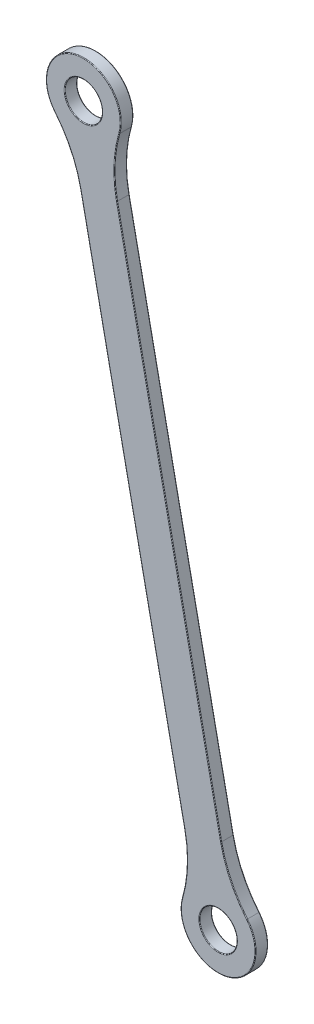
from build123d import *

# Parameters (mm, degrees)
SZKIC2_R                    = 4.5
DODANIE_WYCI_GNI_CIE1_DEPTH = 3
ZAOKR_GLENIE1_R             = 30
ZAOKR_GLENIE2_R             = 30
ZAOKR_GLENIE3_R             = 30
ZAOKR_GLENIE4_R             = 30
ZAOKR_GLENIE5_R             = 0.15


with BuildPart() as part:
    # Szkic2 → Dodanie-wyciągnięcie1 (new body)
    with BuildSketch(Plane.XY):
        with BuildLine():
            ThreePointArc((27.792879551, 56.476790511), (35.605147637, 40.944096516), (36.605872011, 58.301938148))
            Line((36.605872011, 58.301938148), (7.320051345, 199.712808955))
            ThreePointArc((7.320051345, 199.712808955), (-0.492216741, 215.24550295), (-1.492941115, 197.887661317))
            Line((-1.492941115, 197.887661317), (27.792879551, 56.476790511))
        make_face()
        with Locations((33.78, 49.757088976)):
            Circle(SZKIC2_R, mode=Mode.SUBTRACT)
        with Locations((1.332930896, 206.43251049)):
            Circle(SZKIC2_R, mode=Mode.SUBTRACT)
    extrude(amount=DODANIE_WYCI_GNI_CIE1_DEPTH)

    # Zaokrąglenie1
    zaokr_glenie1_edges = [part.edges().sort_by_distance(p)[0] for p in [
        (-1.492941115, 197.887661317, 1.5),
    ]]
    fillet(zaokr_glenie1_edges, radius=ZAOKR_GLENIE1_R)

    # Zaokrąglenie2
    zaokr_glenie2_edges = [part.edges().sort_by_distance(p)[0] for p in [
        (7.320051345, 199.712808955, 1.5),
    ]]
    fillet(zaokr_glenie2_edges, radius=ZAOKR_GLENIE2_R)

    # Zaokrąglenie3
    zaokr_glenie3_edges = [part.edges().sort_by_distance(p)[0] for p in [
        (27.792879551, 56.476790511, 1.5),
    ]]
    fillet(zaokr_glenie3_edges, radius=ZAOKR_GLENIE3_R)

    # Zaokrąglenie4
    zaokr_glenie4_edges = [part.edges().sort_by_distance(p)[0] for p in [
        (36.605872011, 58.301938148, 1.5),
    ]]
    fillet(zaokr_glenie4_edges, radius=ZAOKR_GLENIE4_R)

    # Zaokrąglenie5
    zaokr_glenie5_edges = [part.edges().sort_by_distance(p)[0] for p in [
        (-3.167069104, 206.43251049, 3),
        (-1.706720857, 194.589233339, 0),
        (-1.706720857, 194.589233339, 3),
        (29.28, 49.757088976, 3),
        (-0.492216741, 215.24550295, 0),
        (-0.492216741, 215.24550295, 3),
        (8.82625379, 196.770584778, 0),
        (8.82625379, 196.770584778, 3),
        (35.605147637, 40.944096516, 0),
        (35.605147637, 40.944096516, 3),
        (13.149969218, 127.182225914, 3),
        (13.149969218, 127.182225914, 0),
        (26.286677106, 59.419014688, 0),
        (26.286677106, 59.419014688, 3),
        (21.962961678, 129.007373551, 0),
        (21.962961678, 129.007373551, 3),
        (36.819651752, 61.600366127, 0),
        (36.819651752, 61.600366127, 3),
        (29.28, 49.757088976, 0),
        (-3.167069104, 206.43251049, 0),
    ]]
    fillet(zaokr_glenie5_edges, radius=ZAOKR_GLENIE5_R)


solid = part.part
